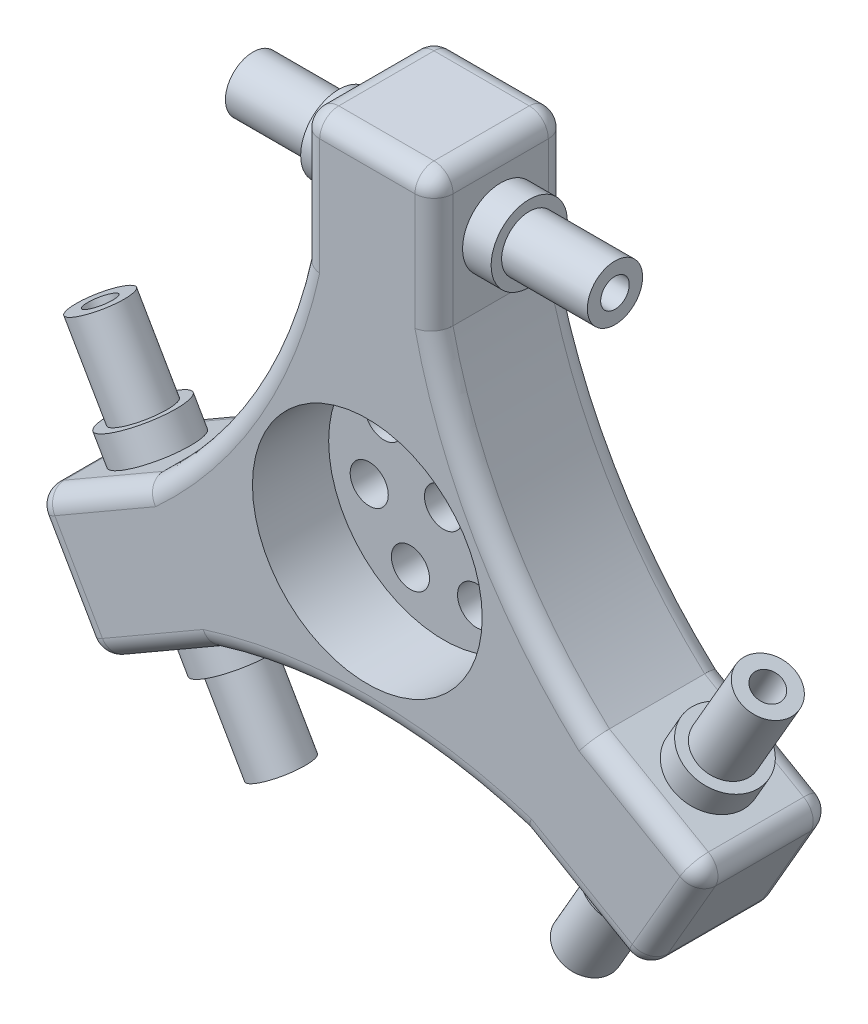
from build123d import *

# Parameters (mm, degrees)
SKETCH2_R           = 2
BOSS_EXTRUDE1_DEPTH = 14
SKETCH7_R           = 12.060749
CUT_EXTRUDE4_DEPTH  = 8
SKETCH8_R           = 2
CUT_EXTRUDE5_DEPTH  = 8
FILLET2_R           = 2
FILLET4_R           = 2
SKETCH10_R          = 4
BOSS_EXTRUDE3_DEPTH = 3
SKETCH13_R          = 4.000853
BOSS_EXTRUDE4_DEPTH = 3
SKETCH15_R          = 2.9
SKETCH15_R_2        = 1.5
BOSS_EXTRUDE5_DEPTH = 9
SKETCH16_R          = 2.9
SKETCH16_R_2        = 1.5
BOSS_EXTRUDE6_DEPTH = 9
CIRPATTERN1_COUNT   = 3


with BuildPart() as part:
    # Sketch2 → Boss-Extrude1 (new body)
    with BuildSketch(Plane.XY):
        with BuildLine():
            Line((-7, 23), (-7, 37))
            Line((-7, 37), (7, 37))
            Line((7, 37), (7, 23))
            ThreePointArc((7, 23), (13.037466, 7.527184), (23.418584, -5.437822))
            Line((23.418584, -5.437822), (35.54294, -12.437822))
            Line((35.54294, -12.437822), (28.54294, -24.562178))
            Line((28.54294, -24.562178), (16.418584, -17.562178))
            ThreePointArc((16.418584, -17.562178), (0, -15.054369), (-16.418584, -17.562178))
            Line((-16.418584, -17.562178), (-28.54294, -24.562178))
            Line((-28.54294, -24.562178), (-35.54294, -12.437822))
            Line((-35.54294, -12.437822), (-23.418584, -5.437822))
            ThreePointArc((-23.418584, -5.437822), (-13.037466, 7.527184), (-7, 23))
        make_face()
        Circle(SKETCH2_R, mode=Mode.SUBTRACT)
    extrude(amount=BOSS_EXTRUDE1_DEPTH)

    # Sketch7 → Cut-Extrude4 (cut)
    with BuildSketch(Plane.XY.offset(14)):
        Circle(SKETCH7_R)
    extrude(amount=-CUT_EXTRUDE4_DEPTH, mode=Mode.SUBTRACT)

    # Sketch8 → Cut-Extrude5 (cut)
    with BuildSketch(Plane.XY.offset(6)):
        with Locations((0, 8)):
            Circle(SKETCH8_R)
        with Locations((6.254652, 4.987918)):
            Circle(SKETCH8_R)
        with Locations((7.799423, -1.780167)):
            Circle(SKETCH8_R)
        with Locations((3.47107, -7.207751)):
            Circle(SKETCH8_R)
        with Locations((-3.47107, -7.207751)):
            Circle(SKETCH8_R)
        with Locations((-7.799423, -1.780167)):
            Circle(SKETCH8_R)
        with Locations((-6.254652, 4.987918)):
            Circle(SKETCH8_R)
    extrude(amount=-CUT_EXTRUDE5_DEPTH, mode=Mode.SUBTRACT)

    # Fillet2
    fillet2_edges = [part.edges().sort_by_distance(p)[0] for p in [
        (32.04294, -18.5, 0),
        (-32.04294, -18.5, 0),
        (0, 37, 0),
        (-32.04294, -18.5, 14),
        (32.04294, -18.5, 14),
        (0, 37, 14),
    ]]
    fillet(fillet2_edges, radius=FILLET2_R)

    # Fillet4
    fillet4_edges = [part.edges().sort_by_distance(p)[0] for p in [
        (7, 29, 0),
        (13.037466, 7.527184, 0),
        (-13.037466, 7.527184, 14),
        (21.614737, -20.562178, 0),
        (0, -15.054369, 0),
        (-28.614737, -8.437822, 0),
        (-13.037466, 7.527184, 0),
        (-28.614737, -8.437822, 14),
        (0, -15.054369, 14),
        (21.614737, -20.562178, 14),
        (13.037466, 7.527184, 14),
        (7, 29, 14),
        (-7, 37, 7),
        (7, 37, 7),
        (-7, 29, 0),
        (-7, 29, 14),
        (-7, 36.414214, 13.414214),
        (-7, 36.414214, 0.585786),
        (28.614737, -8.437822, 0),
        (-21.614737, -20.562178, 0),
        (7, 36.414214, 13.414214),
        (7, 36.414214, 0.585786),
        (-21.614737, -20.562178, 14),
        (28.614737, -8.437822, 14),
        (-28.54294, -24.562178, 7),
        (-35.54294, -12.437822, 7),
        (-28.035634, -24.269285, 13.414214),
        (-28.035634, -24.269285, 0.585786),
        (-35.035634, -12.144929, 13.414214),
        (-35.035634, -12.144929, 0.585786),
        (35.54294, -12.437822, 7),
        (28.54294, -24.562178, 7),
        (35.035634, -12.144929, 13.414214),
        (35.035634, -12.144929, 0.585786),
        (28.035634, -24.269285, 13.414214),
        (28.035634, -24.269285, 0.585786),
    ]]
    fillet(fillet4_edges, radius=FILLET4_R)

    # Sketch10 → Boss-Extrude3 (add)
    with BuildSketch(Plane(origin=(3.5, 6.062178, 0), x_dir=(0.866025403784439, -0.4999999999999995, 0), z_dir=(0.49999999999999944, 0.8660254037844389, 0))):
        with Locations((29.5, -7)):
            Circle(SKETCH10_R)
    boss_extrude3 = extrude(amount=BOSS_EXTRUDE3_DEPTH)

    # Sketch13 → Boss-Extrude4 (add)
    with BuildSketch(Plane(origin=(-3.5, -6.062178, 0), x_dir=(0.8660254037844386, -0.5, 0), z_dir=(-0.5000000000000001, -0.8660254037844387, 0))):
        with Locations(Location((29.5, 7, 0), (0, 0, 180))):
            Circle(SKETCH13_R)
    boss_extrude4 = extrude(amount=BOSS_EXTRUDE4_DEPTH)

    # Sketch15 → Boss-Extrude5 (add)
    with BuildSketch(Plane(origin=(5, 8.660254, 0), x_dir=(0.8660254037844389, -0.4999999999999997, 0), z_dir=(0.4999999999999997, 0.8660254037844389, 0))):
        with Locations(Location((29.5, -7, 0), (0, 0, 180))):
            Circle(SKETCH15_R)
        with Locations(Location((29.5, -7, 0), (0, 0, 180))):
            Circle(SKETCH15_R_2, mode=Mode.SUBTRACT)
    boss_extrude5 = extrude(amount=BOSS_EXTRUDE5_DEPTH)

    # Sketch16 → Boss-Extrude6 (add)
    with BuildSketch(Plane(origin=(-5, -8.660254, 0), x_dir=(0.8660254037844386, -0.4999999999999999, 0), z_dir=(-0.49999999999999994, -0.8660254037844387, 0))):
        with Locations(Location((29.5, 7, 0), (0, 0, 180))):
            Circle(SKETCH16_R)
        with Locations(Location((29.5, 7, 0), (0, 0, 180))):
            Circle(SKETCH16_R_2, mode=Mode.SUBTRACT)
    boss_extrude6 = extrude(amount=BOSS_EXTRUDE6_DEPTH)

    # CirPattern1: Boss-Extrude3, Boss-Extrude4, Boss-Extrude5, Boss-Extrude6 ×3 about axis
    cirpattern1_axis = Axis((0, 0, 0), (0, 0, 1))
    add([boss_extrude3.rotate(cirpattern1_axis, i * 360 / CIRPATTERN1_COUNT) for i in range(1, CIRPATTERN1_COUNT)])
    add([boss_extrude4.rotate(cirpattern1_axis, i * 360 / CIRPATTERN1_COUNT) for i in range(1, CIRPATTERN1_COUNT)])
    add([boss_extrude5.rotate(cirpattern1_axis, i * 360 / CIRPATTERN1_COUNT) for i in range(1, CIRPATTERN1_COUNT)])
    add([boss_extrude6.rotate(cirpattern1_axis, i * 360 / CIRPATTERN1_COUNT) for i in range(1, CIRPATTERN1_COUNT)])


solid = part.part
